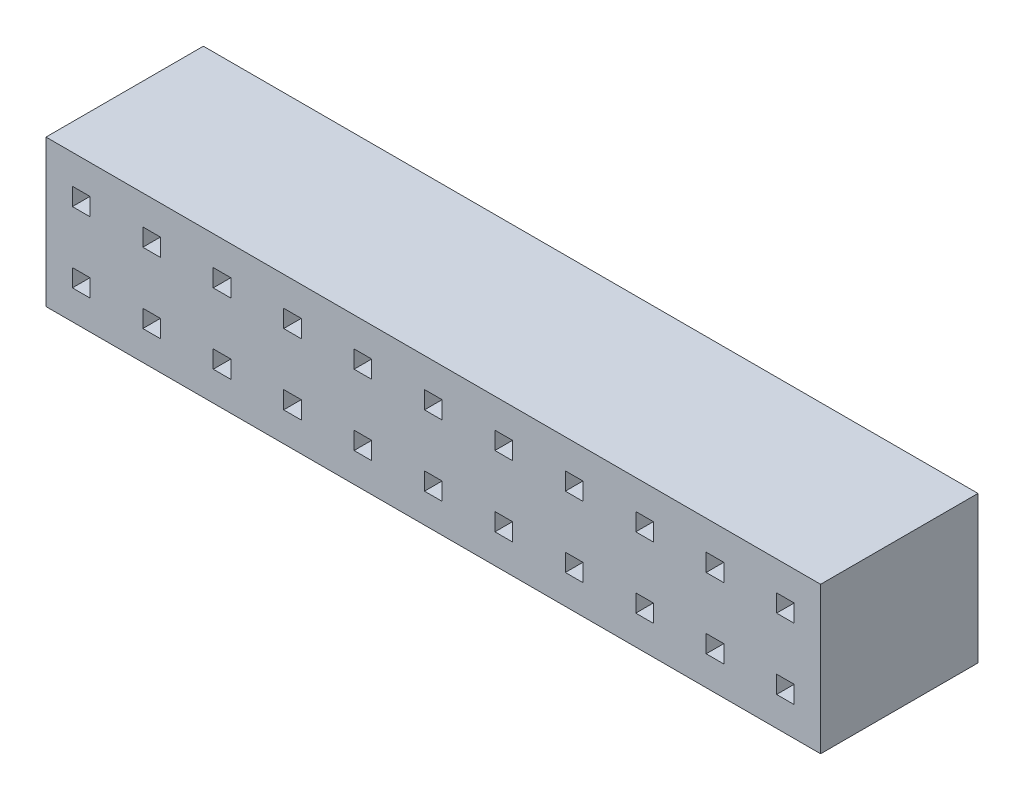
from build123d import *

# Parameters (mm, degrees)
SKETCH1_W           = 22
SKETCH1_H           = 4.17
BOSS_EXTRUDE1_DEPTH = 4.47
SKETCH2_W           = 0.5
SKETCH2_H           = 0.5
CUT_EXTRUDE1_DEPTH  = 4.47


with BuildPart() as part:
    # Sketch1 → Boss-Extrude1 (new body)
    with BuildSketch(Plane.XY):
        with Locations((11, 2)):
            Rectangle(SKETCH1_W, SKETCH1_H)
    extrude(amount=BOSS_EXTRUDE1_DEPTH)

    # Sketch2 → Cut-Extrude1 (cut)
    with BuildSketch(Plane.XY.offset(4.47)):
        with Locations((1, 1)):
            Rectangle(SKETCH2_W, SKETCH2_H)
        with Locations((3, 1)):
            Rectangle(SKETCH2_W, SKETCH2_H)
        with Locations((5, 1)):
            Rectangle(SKETCH2_W, SKETCH2_H)
        with Locations((7, 1)):
            Rectangle(SKETCH2_W, SKETCH2_H)
        with Locations((9, 1)):
            Rectangle(SKETCH2_W, SKETCH2_H)
        with Locations((11, 1)):
            Rectangle(SKETCH2_W, SKETCH2_H)
        with Locations((13, 1)):
            Rectangle(SKETCH2_W, SKETCH2_H)
        with Locations((15, 1)):
            Rectangle(SKETCH2_W, SKETCH2_H)
        with Locations((17, 1)):
            Rectangle(SKETCH2_W, SKETCH2_H)
        with Locations((19, 1)):
            Rectangle(SKETCH2_W, SKETCH2_H)
        with Locations((21, 1)):
            Rectangle(SKETCH2_W, SKETCH2_H)
        with Locations((1, 3)):
            Rectangle(SKETCH2_W, SKETCH2_H)
        with Locations((3, 3)):
            Rectangle(SKETCH2_W, SKETCH2_H)
        with Locations((5, 3)):
            Rectangle(SKETCH2_W, SKETCH2_H)
        with Locations((7, 3)):
            Rectangle(SKETCH2_W, SKETCH2_H)
        with Locations((9, 3)):
            Rectangle(SKETCH2_W, SKETCH2_H)
        with Locations((11, 3)):
            Rectangle(SKETCH2_W, SKETCH2_H)
        with Locations((13, 3)):
            Rectangle(SKETCH2_W, SKETCH2_H)
        with Locations((15, 3)):
            Rectangle(SKETCH2_W, SKETCH2_H)
        with Locations((17, 3)):
            Rectangle(SKETCH2_W, SKETCH2_H)
        with Locations((19, 3)):
            Rectangle(SKETCH2_W, SKETCH2_H)
        with Locations((21, 3)):
            Rectangle(SKETCH2_W, SKETCH2_H)
    extrude(amount=-CUT_EXTRUDE1_DEPTH, mode=Mode.SUBTRACT)


solid = part.part
